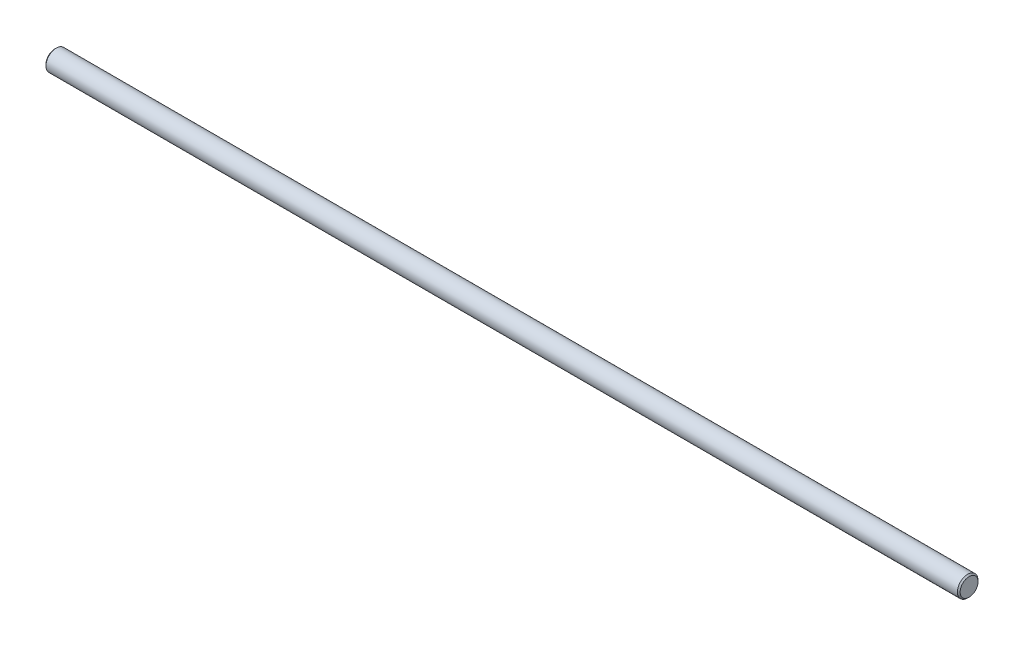
from build123d import *

# Parameters (mm, degrees)
ESQUISSE1_R        = 1.5
BOSS_EXTRU_1_DEPTH = 133
CHANFREIN1_SIZE    = 0.2


with BuildPart() as part:
    # Esquisse1 → Boss.-Extru.1 (new body)
    with BuildSketch(Plane(origin=(0, 0, 0), x_dir=(0, 0, -1), z_dir=(1, 0, 0))):
        Circle(ESQUISSE1_R)
    extrude(amount=BOSS_EXTRU_1_DEPTH)

    # Chanfrein1
    chanfrein1_edges = [part.edges().sort_by_distance(p)[0] for p in [
        (0, 0, 1.5),
        (133, 0, 1.5),
    ]]
    chamfer(chanfrein1_edges, length=CHANFREIN1_SIZE)


solid = part.part
